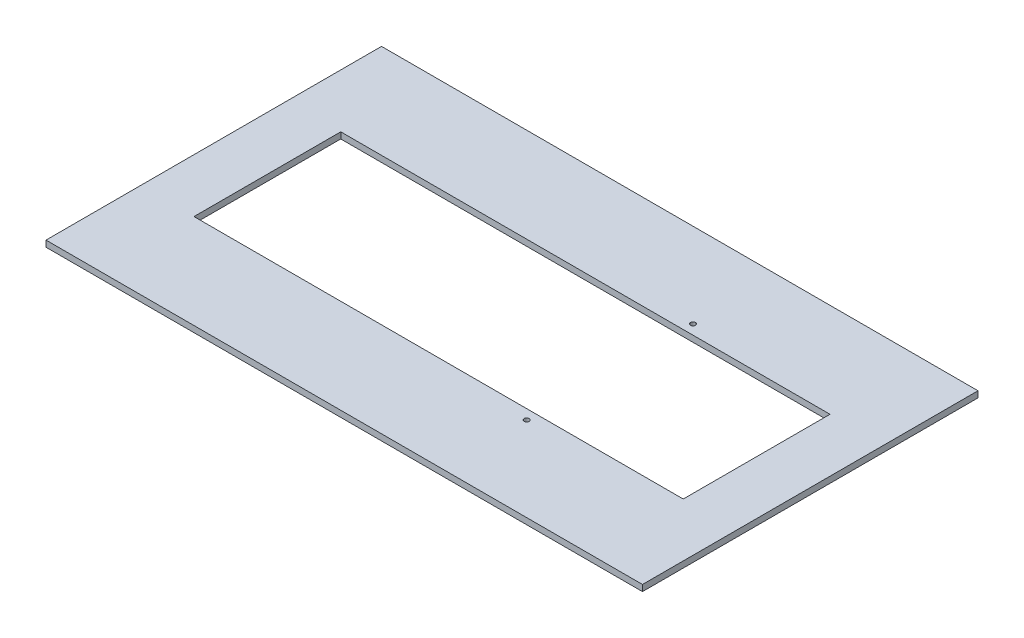
from build123d import *

# Parameters (mm, degrees)
SKETCH1_W           = 609.6
SKETCH1_H           = 342.9
SKETCH1_R           = 2.555
SKETCH1_W_2         = 500
SKETCH1_H_2         = 150
BOSS_EXTRUDE1_DEPTH = 6.35


with BuildPart() as part:
    # Sketch1 → Boss-Extrude1 (new body)
    with BuildSketch(Plane(origin=(0, 0, 0), x_dir=(1, 0, 0), z_dir=(0, 1, 0))):
        with Locations((304.8, 171.45)):
            Rectangle(SKETCH1_W, SKETCH1_H)
        with Locations((404.8, 256.45)):
            Circle(SKETCH1_R, mode=Mode.SUBTRACT)
        with Locations((404.8, 86.45)):
            Circle(SKETCH1_R, mode=Mode.SUBTRACT)
        with Locations((304.8, 171.45)):
            Rectangle(SKETCH1_W_2, SKETCH1_H_2, mode=Mode.SUBTRACT)
    extrude(amount=BOSS_EXTRUDE1_DEPTH)


solid = part.part
